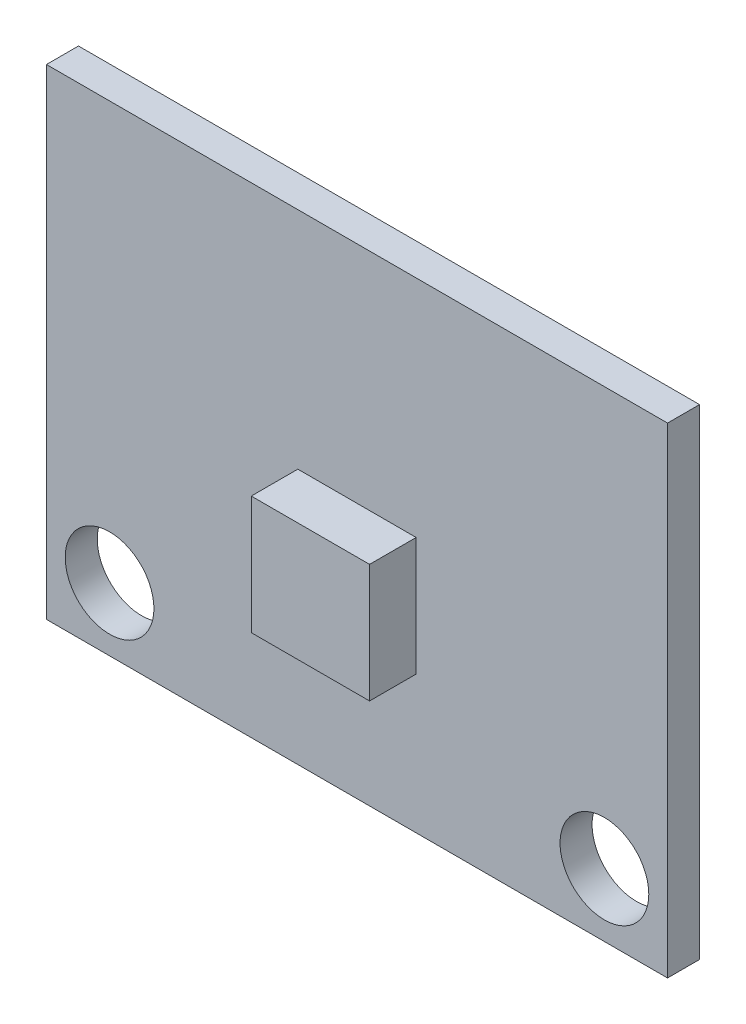
from build123d import *

# Parameters (mm, degrees)
SKETCH1_W           = 21.336
SKETCH1_H           = 16.51
SKETCH1_R           = 1.524
BOSS_EXTRUDE1_DEPTH = 2.7
SKETCH2_OUTSIDE_W   = 28.758
SKETCH2_OUTSIDE_H   = 23.932
SKETCH2_OUTSIDE_W_2 = 4.064
SKETCH2_OUTSIDE_H_2 = 4.064
CUT_EXTRUDE1_DEPTH  = 1.6002


with BuildPart() as part:
    # Sketch1 → Boss-Extrude1 (new body)
    with BuildSketch(Plane.XY):
        with Locations((10.668, 8.255)):
            Rectangle(SKETCH1_W, SKETCH1_H)
        with Locations((2.168, 2.168)):
            Circle(SKETCH1_R, mode=Mode.SUBTRACT)
        with Locations((19.168, 2.168)):
            Circle(SKETCH1_R, mode=Mode.SUBTRACT)
    extrude(amount=BOSS_EXTRUDE1_DEPTH)

    # Sketch2 outside → Cut-Extrude1 (cut)
    with BuildSketch(Plane.XY.offset(2.7)):
        with Locations((10.668, 8.255)):
            Rectangle(SKETCH2_OUTSIDE_W, SKETCH2_OUTSIDE_H)
        with Locations((10.668, 6.7564)):
            Rectangle(SKETCH2_OUTSIDE_W_2, SKETCH2_OUTSIDE_H_2, mode=Mode.SUBTRACT)
    extrude(amount=-CUT_EXTRUDE1_DEPTH, mode=Mode.SUBTRACT)


solid = part.part
